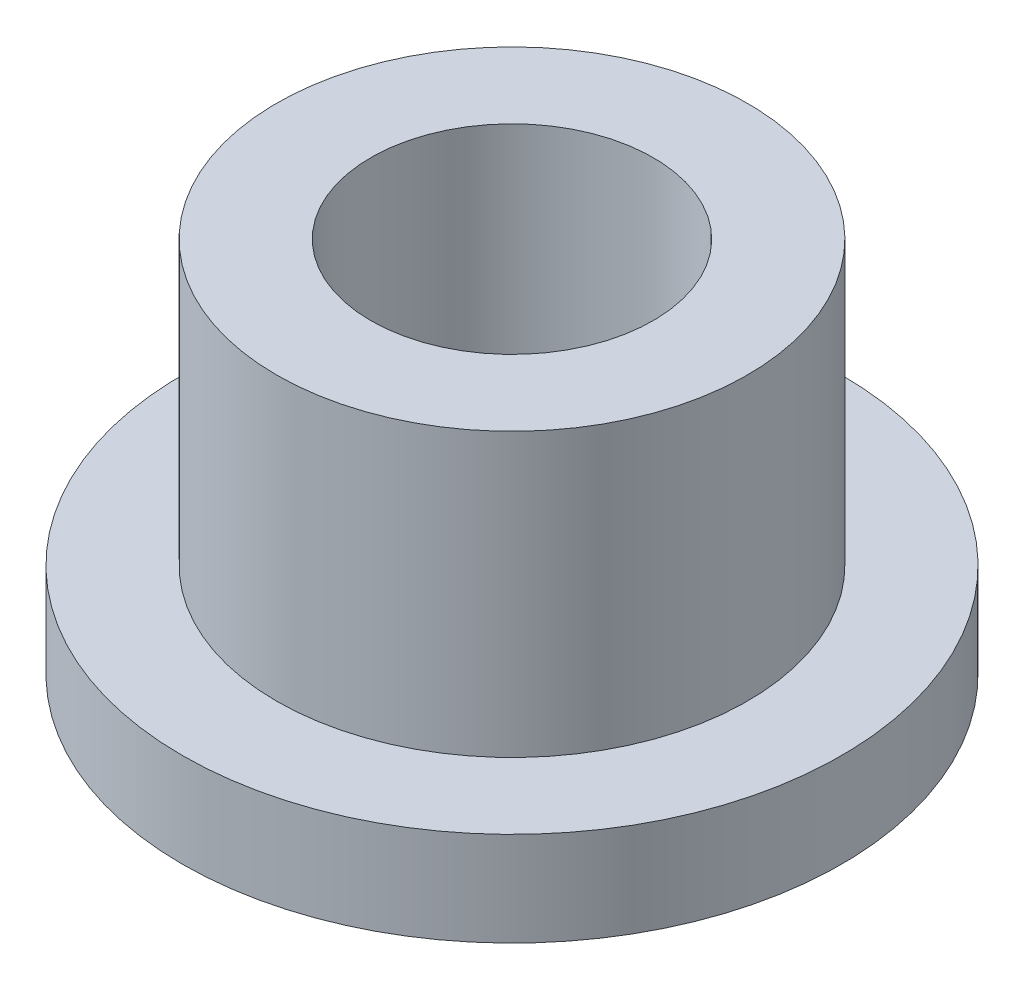
from build123d import *

# Parameters (mm, degrees)
SKETCH2_R           = 3.96875
SKETCH2_R_2         = 2.38125
BOSS_EXTRUDE1_DEPTH = 6.35
SKETCH3_R           = 5.55625
SKETCH3_R_2         = 3.96875
BOSS_EXTRUDE2_DEPTH = 1.5875


with BuildPart() as part:
    # Sketch2 → Boss-Extrude1 (new body)
    with BuildSketch(Plane(origin=(0, 0, 0), x_dir=(1, 0, 0), z_dir=(0, 1, 0))):
        Circle(SKETCH2_R)
        Circle(SKETCH2_R_2, mode=Mode.SUBTRACT)
    extrude(amount=BOSS_EXTRUDE1_DEPTH)

    # Sketch3 → Boss-Extrude2 (add)
    with BuildSketch(Plane(origin=(0, 0, 0), x_dir=(1, 0, 0), z_dir=(0, 1, 0))):
        Circle(SKETCH3_R)
        Circle(SKETCH3_R_2, mode=Mode.SUBTRACT)
    extrude(amount=BOSS_EXTRUDE2_DEPTH)


solid = part.part
